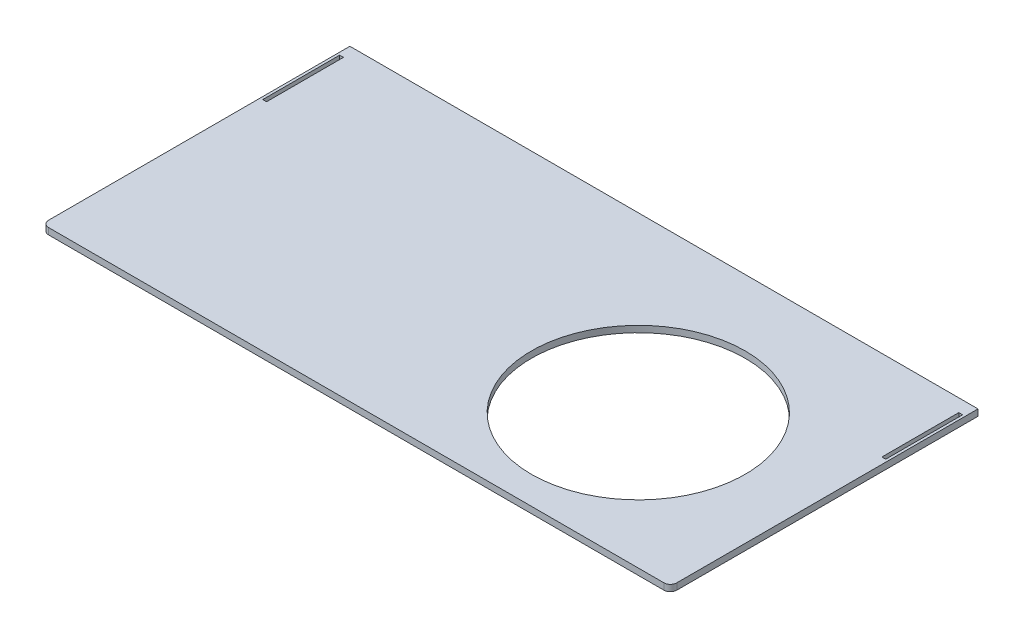
from build123d import *

# Parameters (mm, degrees)
CROQUIS2_W              = 622.3
CROQUIS2_H              = 304.8
SALIENTE_EXTRUIR1_DEPTH = 6.35
REDONDEO1_R             = 6.35
CROQUIS4_W              = 3.81
CROQUIS4_H              = 76.2
CORTAR_EXTRUIR2_DEPTH   = 7.35
CROQUIS5_R              = 105.918
CORTAR_EXTRUIR3_DEPTH   = 7.35


with BuildPart() as part:
    # Croquis2 → Saliente-Extruir1 (new body)
    with BuildSketch(Plane(origin=(0, 0, 0), x_dir=(1, 0, 0), z_dir=(0, 1, 0))):
        Rectangle(CROQUIS2_W, CROQUIS2_H)
    extrude(amount=SALIENTE_EXTRUIR1_DEPTH)

    # Redondeo1
    redondeo1_edges = [part.edges().sort_by_distance(p)[0] for p in [
        (311.15, 3.175, 152.4),
        (-311.15, 3.175, 152.4),
    ]]
    fillet(redondeo1_edges, radius=REDONDEO1_R)

    # Croquis4 → Cortar-Extruir2 (cut, through all)
    with BuildSketch(Plane(origin=(0, 6.35, 0), x_dir=(1, 0, 0), z_dir=(0, 1, 0))):
        with Locations((-306.705, 101.6)):
            Rectangle(CROQUIS4_W, CROQUIS4_H)
        with Locations((306.705, 101.6)):
            Rectangle(CROQUIS4_W, CROQUIS4_H)
    extrude(amount=-CORTAR_EXTRUIR2_DEPTH, mode=Mode.SUBTRACT)

    # Croquis5 → Cortar-Extruir3 (cut, through all)
    with BuildSketch(Plane(origin=(0, 6.35, 0), x_dir=(1, 0, 0), z_dir=(0, 1, 0))):
        with Locations((146.05, -19.05)):
            Circle(CROQUIS5_R)
    extrude(amount=-CORTAR_EXTRUIR3_DEPTH, mode=Mode.SUBTRACT)


solid = part.part
